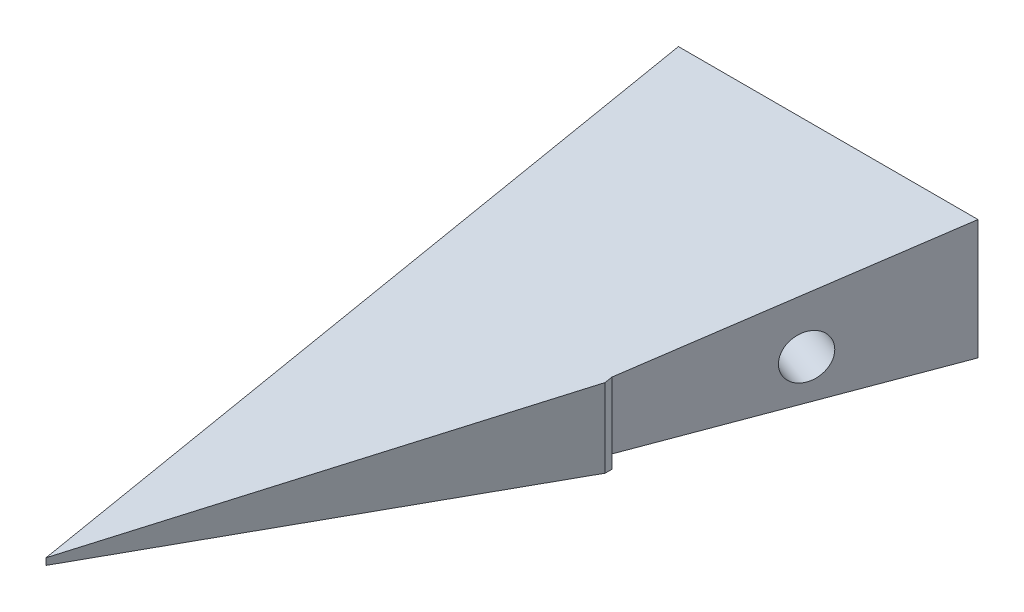
from build123d import *

# Parameters (mm, degrees)
ESBO_O1_W                                      = 130
ESBO_O1_H                                      = 20
RESSALTO_EXTRUS_O1_DEPTH                       = 95
CORTE_EXTRUS_O2_REACH                          = 22
CORTE_EXTRUS_O4_DEPTH                          = 1
CORTE_EXTRUS_O4_DEPTH_BACK                     = 46
BROCA_DE_ROSQUEAR_DE_CANO_PARA_TARRAXA_D_D     = 6.579997
BROCA_DE_ROSQUEAR_DE_CANO_PARA_TARRAXA_D_DEPTH = 10
BROCA_DE_ROSQUEAR_DE_CANO_PARA_TARRAXA_D_TIP   = 1.976830535
BROCA_DE_ROSQUEAR_DE_CANO_PARA_TARRA_2_D       = 6.579997
BROCA_DE_ROSQUEAR_DE_CANO_PARA_TARRA_2_DEPTH   = 10
BROCA_DE_ROSQUEAR_DE_CANO_PARA_TARRA_2_TIP     = 1.976830535
ESBO_O42_W                                     = 45
ESBO_O42_H                                     = 2
CORTE_EXTRUS_O5_DEPTH                          = 40


with BuildPart() as part:
    # Esboço1 → Ressalto-extrusão1 (new body)
    with BuildSketch(Plane.XY):
        Rectangle(ESBO_O1_W, ESBO_O1_H)
    extrude(amount=RESSALTO_EXTRUS_O1_DEPTH)

    # Esboço2 → Corte-extrusão2 (cut, up to next)
    with BuildSketch(Plane(origin=(0, 10, 0), x_dir=(1, 0, 0), z_dir=(0, 1, 0)), mode=Mode.PRIVATE) as corte_extrus_o2_sk1:
        Polygon((65, 0), (-20, 0), (-35, -40), (-35, -41), (-65, -95), (65, -95), align=None)
    corte_extrus_o2_tool1 = extrude(corte_extrus_o2_sk1.sketch, amount=-CORTE_EXTRUS_O2_REACH, mode=Mode.PRIVATE) & part.part
    add(corte_extrus_o2_tool1.solids().sort_by_distance((11.493506, 10, 50.911089))[0], mode=Mode.SUBTRACT)

    # Esboço13 → Corte-extrusão4 (cut, two sides)
    with BuildSketch(Plane.ZY.offset(65)) as corte_extrus_o4_sk:
        Polygon((-200.200134404, 50.040026881), (0, 10), (95, -9), (295.200134404, -49.040026881), (375.280188165, 351.360241926), (-120.120080642, 450.440295688), align=None)
    extrude(amount=CORTE_EXTRUS_O4_DEPTH, mode=Mode.SUBTRACT)
    extrude(corte_extrus_o4_sk.sketch, amount=-CORTE_EXTRUS_O4_DEPTH_BACK, mode=Mode.SUBTRACT)

    # Broca de rosquear de cano para tarraxa d
    with Locations(Plane.ZY.offset(65)):
        with Locations((20, -2)):
            Hole(BROCA_DE_ROSQUEAR_DE_CANO_PARA_TARRAXA_D_D / 2, depth=BROCA_DE_ROSQUEAR_DE_CANO_PARA_TARRAXA_D_DEPTH)
            with Locations((0, 0, -(BROCA_DE_ROSQUEAR_DE_CANO_PARA_TARRAXA_D_DEPTH + BROCA_DE_ROSQUEAR_DE_CANO_PARA_TARRAXA_D_TIP / 2))):  # 118° drill point
                Cone(0, BROCA_DE_ROSQUEAR_DE_CANO_PARA_TARRAXA_D_D / 2, BROCA_DE_ROSQUEAR_DE_CANO_PARA_TARRAXA_D_TIP, mode=Mode.SUBTRACT)

    # Broca de rosquear de cano para tarra 2
    with Locations(Plane(origin=(-17.534246575, 0, -6.575342466), x_dir=(0.351123442, 0, -0.936329178), z_dir=(0.936329178, 0, 0.351123442))):
        with Locations((-27.022468832, -2)):
            Hole(BROCA_DE_ROSQUEAR_DE_CANO_PARA_TARRA_2_D / 2, depth=BROCA_DE_ROSQUEAR_DE_CANO_PARA_TARRA_2_DEPTH)
            with Locations((0, 0, -(BROCA_DE_ROSQUEAR_DE_CANO_PARA_TARRA_2_DEPTH + BROCA_DE_ROSQUEAR_DE_CANO_PARA_TARRA_2_TIP / 2))):  # 118° drill point
                Cone(0, BROCA_DE_ROSQUEAR_DE_CANO_PARA_TARRA_2_D / 2, BROCA_DE_ROSQUEAR_DE_CANO_PARA_TARRA_2_TIP, mode=Mode.SUBTRACT)

    # Esboço42 → Corte-extrusão5 (cut)
    with BuildSketch(Plane(origin=(0, 0, 0), x_dir=(-1, 0, 0), z_dir=(0, 0, -1))):
        with Locations((42.5, -9)):
            Rectangle(ESBO_O42_W, ESBO_O42_H)
    extrude(amount=-CORTE_EXTRUS_O5_DEPTH, mode=Mode.SUBTRACT)


solid = part.part
